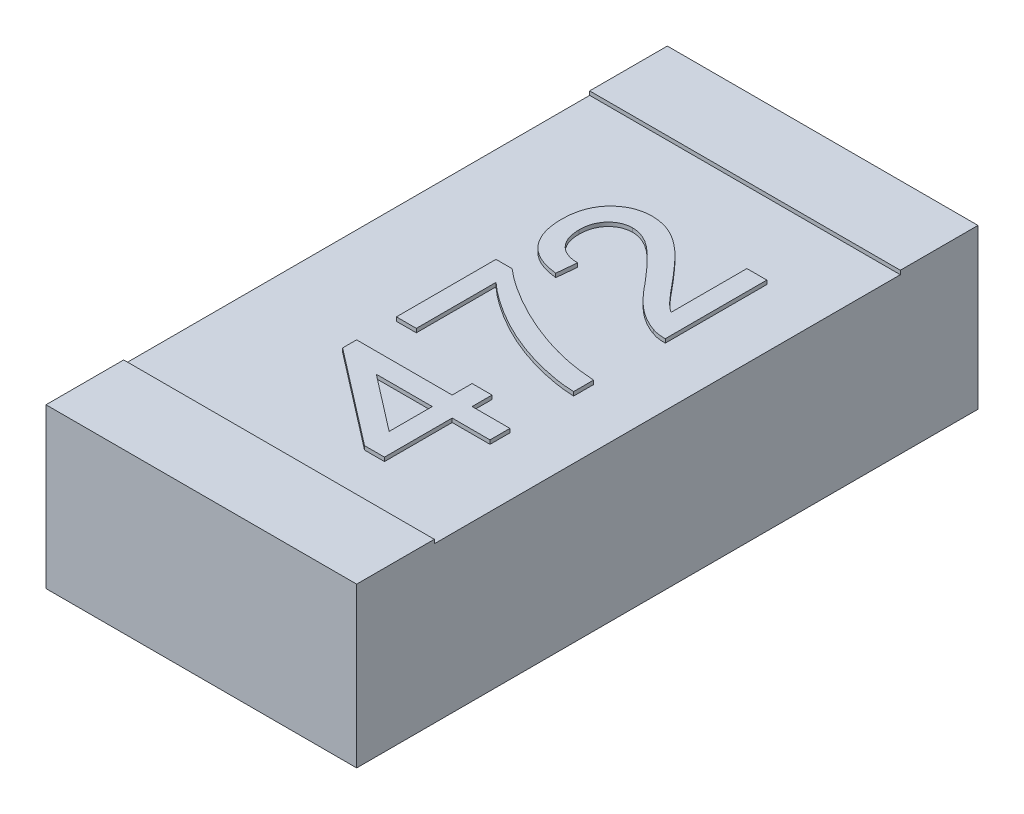
from build123d import *

# Parameters (mm, degrees)
SKETCH_1_W      = 0.8
SKETCH_1_H      = 1.6
EXTRUDE_1_DEPTH = 0.4
SKETCH_2_W      = 0.8
SKETCH_2_H      = 0.2
EXTRUDE_2_DEPTH = 0.01


with BuildPart() as part:
    # Эскиз1 → Бобышка-Вытянуть1 (new body)
    with BuildSketch(Plane(origin=(0, 0, 0), x_dir=(1, 0, 0), z_dir=(0, 1, 0))):
        with Locations((-3.546666667, 0.56)):
            Rectangle(SKETCH_1_W, SKETCH_1_H)
    extrude(amount=EXTRUDE_1_DEPTH)

    # Эскиз2 → Бобышка-Вытянуть2 (add)
    with BuildSketch(Plane(origin=(0, 0.4, 0), x_dir=(1, 0, 0), z_dir=(0, 1, 0))):
        with Locations((-3.546666667, 1.26)):
            Rectangle(SKETCH_2_W, SKETCH_2_H)
        with Locations((-3.546666667, -0.14)):
            Rectangle(SKETCH_2_W, SKETCH_2_H)
        with BuildLine():
            Line((-3.347948718, 0.96619925), (-3.296666667, 0.96619925))
            Line((-3.296666667, 0.96619925), (-3.296666667, 0.704660789))
            add(Edge.make_bspline(
                [(-3.296666667, 0.704660789), (-3.299714721, 0.704653678), (-3.305774032, 0.704639541), (-3.314770725, 0.705690594), (-3.323656392, 0.707274517), (-3.329375637, 0.709109309), (-3.33224359, 0.710029379)],
                knots=[0, 0, 0, 0, 1.010600758, 2.009000657, 3.001600101, 4, 4, 4, 4], degree=3))
            add(Edge.make_bspline(
                [(-3.33224359, 0.710029379), (-3.336932362, 0.711721718), (-3.346456969, 0.715159476), (-3.360187488, 0.722229591), (-3.373915942, 0.730387016), (-3.38506487, 0.738436812), (-3.393967559, 0.745776399), (-3.400931315, 0.751934453), (-3.408059998, 0.758757865), (-3.415351725, 0.766242173), (-3.422853891, 0.774315053), (-3.430591465, 0.782987605), (-3.438420265, 0.792362213), (-3.443609519, 0.798906673), (-3.446266026, 0.802256943)],
                knots=[0, 0, 0, 0, 1.204682444, 2.447149603, 3.728063212, 5.065745198, 5.768097617, 6.518745349, 7.313897871, 8.154576377, 9.046034033, 9.979646649, 10.965731253, 12, 12, 12, 12], degree=3))
            add(Edge.make_bspline(
                [(-3.446266026, 0.802256943), (-3.45059804, 0.807403785), (-3.458939607, 0.817314355), (-3.471317716, 0.831309641), (-3.482811507, 0.84409203), (-3.493622362, 0.855458095), (-3.503645651, 0.865500412), (-3.512857936, 0.874243792), (-3.521232754, 0.881759597), (-3.529066081, 0.887968052), (-3.536461335, 0.89316514), (-3.543635002, 0.897677348), (-3.550838276, 0.901299603), (-3.55793436, 0.904408042), (-3.564951278, 0.906819597), (-3.571951879, 0.908516787), (-3.578869895, 0.909613508), (-3.583495036, 0.909731149), (-3.585769231, 0.909788994)],
                knots=[0, 0, 0, 0, 1.782511555, 3.432339066, 4.950556168, 6.337242158, 7.588364383, 8.709771971, 9.70247892, 10.569050646, 11.3564271, 12.096888545, 12.812232926, 13.490631961, 14.148641375, 14.7751826, 15.397753892, 16, 16, 16, 16], degree=3))
            add(Edge.make_bspline(
                [(-3.585769231, 0.909788994), (-3.588017262, 0.909733321), (-3.592427777, 0.909624092), (-3.598882449, 0.908587524), (-3.605098798, 0.907145011), (-3.610963294, 0.904811094), (-3.616655693, 0.902039253), (-3.621990535, 0.898447859), (-3.627169376, 0.894382659), (-3.631921404, 0.889633661), (-3.636373741, 0.884482269), (-3.640098955, 0.87875047), (-3.643320365, 0.872720515), (-3.646025422, 0.866331302), (-3.647986405, 0.859488111), (-3.649417628, 0.852277685), (-3.650323049, 0.844694102), (-3.650448604, 0.839519116), (-3.650512821, 0.836872327)],
                knots=[0, 0, 0, 0, 0.987973548, 1.938350371, 2.870100611, 3.788647624, 4.708095761, 5.649791829, 6.611214459, 7.599816467, 8.600146238, 9.60047601, 10.599079585, 11.604913276, 12.645813302, 13.724097821, 14.835971573, 16, 16, 16, 16], degree=3))
            add(Edge.make_bspline(
                [(-3.650512821, 0.836872327), (-3.650448919, 0.83409195), (-3.65032386, 0.828650546), (-3.649414862, 0.820696253), (-3.648022672, 0.8131466), (-3.645906086, 0.806012387), (-3.643203711, 0.799339736), (-3.639949776, 0.793050051), (-3.636123517, 0.787190009), (-3.631628174, 0.781842581), (-3.626633448, 0.777010688), (-3.621196547, 0.772724047), (-3.615197435, 0.769184165), (-3.608751543, 0.766323888), (-3.601899236, 0.763966526), (-3.594572456, 0.762276504), (-3.586780767, 0.761351474), (-3.581444563, 0.761165878), (-3.578717949, 0.761071045)],
                knots=[0, 0, 0, 0, 1.130801575, 2.213061782, 3.252933619, 4.249917472, 5.234510032, 6.17726912, 7.126517163, 8.075267631, 9.012689889, 9.949419277, 10.884824487, 11.837981854, 12.813782694, 13.828488442, 14.890433304, 16, 16, 16, 16], degree=3))
            Line((-3.578717949, 0.761071045), (-3.583846154, 0.709788994))
            add(Edge.make_bspline(
                [(-3.583846154, 0.709788994), (-3.588315516, 0.710313674), (-3.597010277, 0.711334394), (-3.609603065, 0.71387702), (-3.621318367, 0.717446081), (-3.632317675, 0.721718641), (-3.642420269, 0.727067939), (-3.6518288, 0.733149711), (-3.660309503, 0.740238528), (-3.66800975, 0.74812715), (-3.674692755, 0.756896835), (-3.680625157, 0.766339148), (-3.685570315, 0.776564159), (-3.689671345, 0.787474273), (-3.692781161, 0.799101959), (-3.695011662, 0.811428697), (-3.696386448, 0.824474892), (-3.696571928, 0.833423413), (-3.696666667, 0.837994122)],
                knots=[0, 0, 0, 0, 1.130730993, 2.199739822, 3.223355253, 4.205635214, 5.160465258, 6.091399258, 7.016214058, 7.932437584, 8.856204186, 9.781944312, 10.73064304, 11.705670886, 12.707145581, 13.751268262, 14.851396981, 16, 16, 16, 16], degree=3))
            add(Edge.make_bspline(
                [(-3.696666667, 0.837994122), (-3.696587462, 0.842619542), (-3.69643317, 0.851629887), (-3.694854453, 0.864759408), (-3.692395617, 0.877147474), (-3.688968751, 0.888839497), (-3.684475113, 0.89976641), (-3.678984885, 0.909936577), (-3.672551696, 0.919397044), (-3.66509805, 0.927989176), (-3.656961938, 0.935738546), (-3.648276111, 0.94252391), (-3.639070222, 0.948230333), (-3.629462356, 0.952997663), (-3.619322428, 0.956642507), (-3.608726584, 0.959140325), (-3.597657153, 0.96085828), (-3.590102935, 0.960999181), (-3.58625, 0.961071045)],
                knots=[0, 0, 0, 0, 1.195413282, 2.328672114, 3.413490698, 4.457927086, 5.473612634, 6.462365753, 7.441157041, 8.42539015, 9.397434444, 10.3422866, 11.269742116, 12.193178192, 13.110630063, 14.048592791, 15.004708964, 16, 16, 16, 16], degree=3))
            add(Edge.make_bspline(
                [(-3.58625, 0.961071045), (-3.582291584, 0.96096106), (-3.574366015, 0.960740846), (-3.562521371, 0.959013923), (-3.550822762, 0.956087583), (-3.539112888, 0.952123006), (-3.527293622, 0.946848171), (-3.51526789, 0.940068453), (-3.502985529, 0.931735692), (-3.492609351, 0.923636931), (-3.483861017, 0.916172703), (-3.476660227, 0.909501035), (-3.46892387, 0.901874967), (-3.460562632, 0.893403332), (-3.451769433, 0.883875186), (-3.442303631, 0.873514434), (-3.432403514, 0.862105379), (-3.425640701, 0.854184786), (-3.422147436, 0.850093481)],
                knots=[0, 0, 0, 0, 0.927158598, 1.856363277, 2.797335015, 3.749167701, 4.749227661, 5.825023649, 6.979171586, 8.223362362, 8.906844726, 9.672958766, 10.52256342, 11.451810239, 12.461281865, 13.559912207, 14.739596516, 16, 16, 16, 16], degree=3))
            add(Edge.make_bspline(
                [(-3.422147436, 0.850093481), (-3.4193034, 0.84658306), (-3.413869486, 0.839875929), (-3.405878123, 0.830460357), (-3.398751822, 0.821860159), (-3.392389028, 0.814181288), (-3.386661568, 0.807485977), (-3.381635635, 0.801770745), (-3.377396759, 0.79693144), (-3.370792529, 0.789705237), (-3.361369328, 0.780582945), (-3.352291495, 0.773780445), (-3.347948718, 0.770526173)],
                knots=[0, 0, 0, 0, 1.242067915, 2.373138023, 3.395138797, 4.312776638, 5.114836229, 5.81737152, 6.405241861, 6.883397567, 8.50903741, 10, 10, 10, 10], degree=3))
            Line((-3.347948718, 0.770526173), (-3.347948718, 0.96619925))
        make_face()
        with BuildLine():
            Line((-3.64025641, 0.407224891), (-3.691538462, 0.407224891))
            Line((-3.691538462, 0.407224891), (-3.691538462, 0.663635148))
            Line((-3.691538462, 0.663635148), (-3.650032051, 0.663635148))
            add(Edge.make_bspline(
                [(-3.650032051, 0.663635148), (-3.646502021, 0.660616545), (-3.639284349, 0.654444563), (-3.627787933, 0.645502899), (-3.61554742, 0.636515998), (-3.60244882, 0.627635735), (-3.588592227, 0.61876604), (-3.573973239, 0.609833167), (-3.558531576, 0.600959048), (-3.536884197, 0.589255431), (-3.509140266, 0.575362882), (-3.475000597, 0.560856757), (-3.440531826, 0.54800689), (-3.417091589, 0.54116578), (-3.405400641, 0.537753738)],
                knots=[0, 0, 0, 0, 0.6032745, 1.233484441, 1.891357215, 2.57557336, 3.288734553, 4.028369461, 4.800843345, 5.601920993, 7.224937043, 8.829018402, 10.418455404, 12, 12, 12, 12], degree=3))
            add(Edge.make_bspline(
                [(-3.405400641, 0.537753738), (-3.396957321, 0.535541077), (-3.379780473, 0.531039703), (-3.353107004, 0.526112085), (-3.325295894, 0.522302305), (-3.306318462, 0.520806275), (-3.296666667, 0.520045404)],
                knots=[0, 0, 0, 0, 0.948866074, 1.930345965, 2.947387709, 4, 4, 4, 4], degree=3))
            Line((-3.296666667, 0.520045404), (-3.296666667, 0.468763353))
            add(Edge.make_bspline(
                [(-3.296666667, 0.468763353), (-3.300648464, 0.468886356), (-3.308836796, 0.469139305), (-3.321419039, 0.470257863), (-3.334626523, 0.471747682), (-3.34841463, 0.473851923), (-3.362811345, 0.47652659), (-3.377831929, 0.479713791), (-3.393445276, 0.483520299), (-3.415092317, 0.48914961), (-3.442310543, 0.497512223), (-3.474498855, 0.509677325), (-3.506137168, 0.52371432), (-3.531836702, 0.536987949), (-3.551768129, 0.548460586), (-3.566250592, 0.557079737), (-3.580059398, 0.565975659), (-3.593287523, 0.574947686), (-3.605942611, 0.584003547), (-3.617907266, 0.593326123), (-3.629421628, 0.60264096), (-3.636676667, 0.609144268), (-3.64025641, 0.612353097)],
                knots=[0, 0, 0, 0, 0.630310263, 1.296195935, 1.998233977, 2.733510572, 3.502865957, 4.315300234, 5.16313825, 6.045860881, 7.854817038, 9.665969389, 11.488229695, 13.329548187, 14.240214963, 15.127489952, 15.996309606, 16.839233987, 17.656863512, 18.458360632, 19.239332369, 20, 20, 20, 20], degree=3))
            Line((-3.64025641, 0.612353097), (-3.64025641, 0.407224891))
        make_face()
        Polygon((-3.296666667, 0.253378738), (-3.394102564, 0.253378738), (-3.394102564, 0.079019763), (-3.445384615, 0.079019763), (-3.691538462, 0.268763353), (-3.691538462, 0.304660789), (-3.445384615, 0.304660789), (-3.445384615, 0.35594284), (-3.394102564, 0.35594284), (-3.394102564, 0.304660789), (-3.296666667, 0.304660789), align=None)
        Polygon((-3.445384615, 0.253378738), (-3.589455128, 0.253378738), (-3.445384615, 0.142321045), align=None, mode=Mode.SUBTRACT)
    extrude(amount=EXTRUDE_2_DEPTH)


solid = part.part
